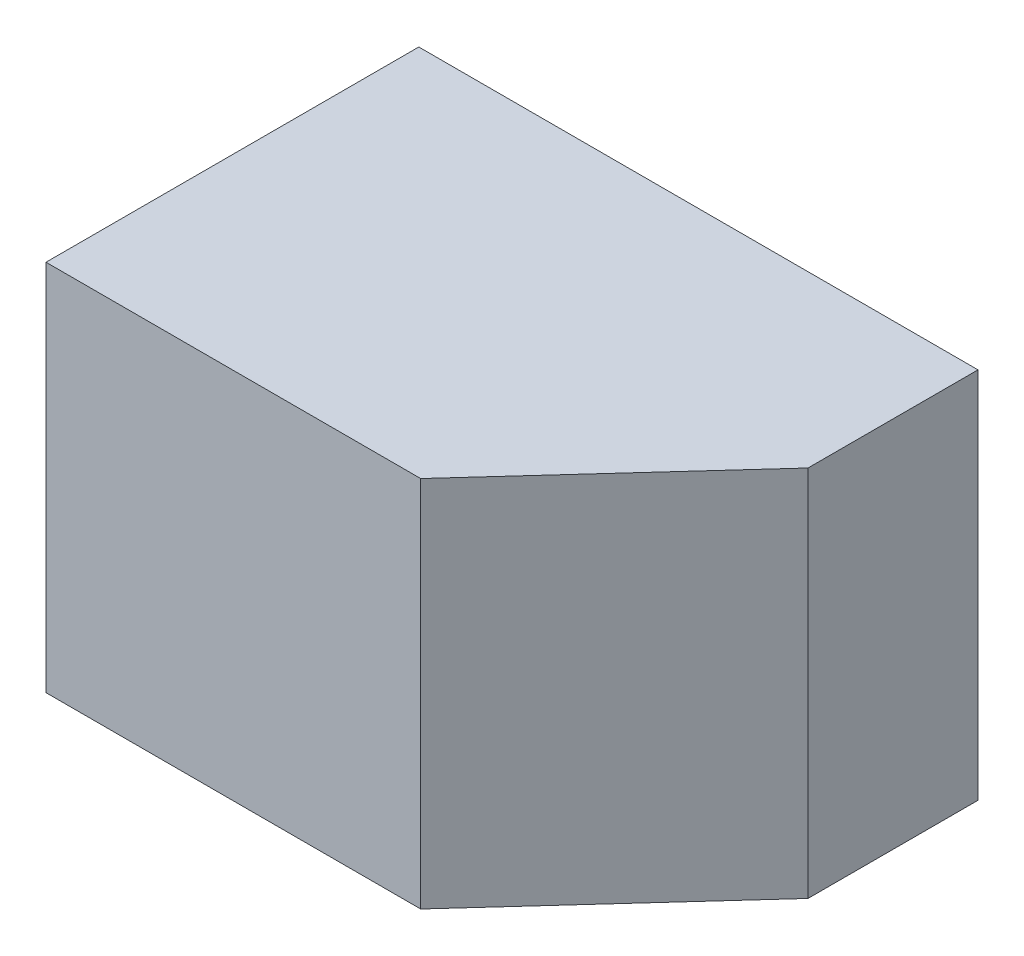
from build123d import *

# Parameters (mm, degrees)
SKETCH_1_W          = 10
SKETCH_1_H          = 10
EXTRUDE_1_DEPTH     = 15
CUT_EXTRUDE_1_DEPTH = 15


with BuildPart() as part:
    # Эскиз1 → Бобышка-Вытянуть1 (new body)
    with BuildSketch(Plane(origin=(0, 0, 0), x_dir=(0, 0, -1), z_dir=(1, 0, 0))):
        with Locations((5, 5)):
            Rectangle(SKETCH_1_W, SKETCH_1_H)
    extrude(amount=EXTRUDE_1_DEPTH)

    # Эскиз2 → Вырез-Вытянуть1 (cut)
    with BuildSketch(Plane(origin=(0, 10, 0), x_dir=(1, 0, 0), z_dir=(0, 1, 0))):
        Polygon((10.050486539, 0), (15, 5.440128208), (15, 0), align=None)
    extrude(amount=-CUT_EXTRUDE_1_DEPTH, mode=Mode.SUBTRACT)


solid = part.part
